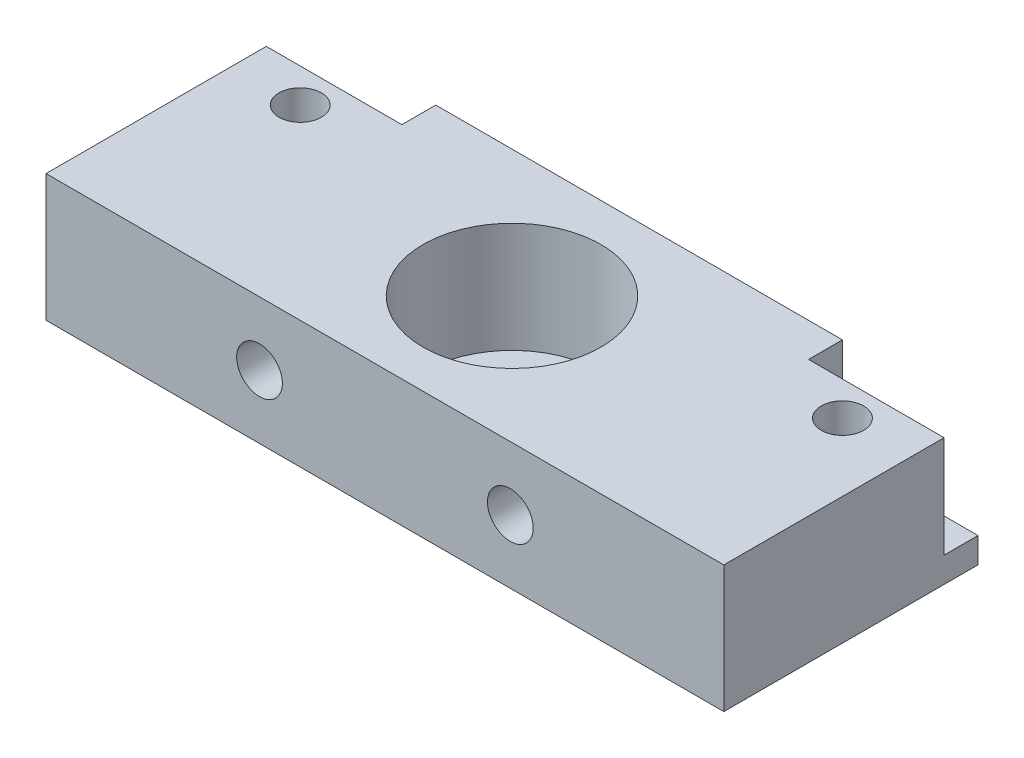
from build123d import *

# Parameters (mm, degrees)
SKETCH1_W           = 101.6
SKETCH1_H           = 38.1
BOSS_EXTRUDE1_DEPTH = 19.05
SKETCH2_R           = 3.175
CUT_EXTRUDE1_DEPTH  = 16.51
CUT_EXTRUDE2_REACH  = 40.1
SKETCH3_R           = 3.429
SKETCH4_R           = 13.335
CUT_EXTRUDE3_DEPTH  = 16.51
SKETCH5_R           = 3.556
CUT_EXTRUDE4_DEPTH  = 20.05
SKETCH6_W           = 20.32
SKETCH6_H           = 5.08
CUT_EXTRUDE5_DEPTH  = 15.24


with BuildPart() as part:
    # Sketch1 → Boss-Extrude1 (new body)
    with BuildSketch(Plane(origin=(0, 0, 0), x_dir=(1, 0, 0), z_dir=(0, 1, 0))):
        with Locations((12.918491372, -8.273443983)):
            Rectangle(SKETCH1_W, SKETCH1_H)
    extrude(amount=BOSS_EXTRUDE1_DEPTH)

    # Sketch2 → Cut-Extrude1 (cut)
    with BuildSketch(Plane(origin=(0, 19.05, 0), x_dir=(1, 0, 0), z_dir=(0, 1, 0))):
        with Locations((-27.721508628, 0.616556017)):
            Circle(SKETCH2_R)
        with Locations((53.558491372, 0.616556017)):
            Circle(SKETCH2_R)
    extrude(amount=-CUT_EXTRUDE1_DEPTH, mode=Mode.SUBTRACT)

    # Sketch3 → Cut-Extrude2 (cut, up to next)
    with BuildSketch(Plane.XY.offset(27.323443983), mode=Mode.PRIVATE) as cut_extrude2_sk1:
        with Locations((-5.877508628, 9.525)):
            Circle(SKETCH3_R)
    cut_extrude2_tool1 = extrude(cut_extrude2_sk1.sketch, amount=-CUT_EXTRUDE2_REACH, mode=Mode.PRIVATE) & part.part
    add(cut_extrude2_tool1.solids().sort_by_distance((-5.877509, 9.525, 27.323444))[0], mode=Mode.SUBTRACT)
    # Sketch3 → Cut-Extrude2 (cut, up to next)
    with BuildSketch(Plane.XY.offset(27.323443983), mode=Mode.PRIVATE) as cut_extrude2_sk2:
        with Locations((31.714491372, 9.525)):
            Circle(SKETCH3_R)
    cut_extrude2_tool2 = extrude(cut_extrude2_sk2.sketch, amount=-CUT_EXTRUDE2_REACH, mode=Mode.PRIVATE) & part.part
    add(cut_extrude2_tool2.solids().sort_by_distance((31.714491, 9.525, 27.323444))[0], mode=Mode.SUBTRACT)

    # Sketch4 → Cut-Extrude3 (cut)
    with BuildSketch(Plane(origin=(0, 19.05, 0), x_dir=(1, 0, 0), z_dir=(0, 1, 0))):
        with Locations((12.918491372, -8.273443983)):
            Circle(SKETCH4_R)
    extrude(amount=-CUT_EXTRUDE3_DEPTH, mode=Mode.SUBTRACT)

    # Sketch5 → Cut-Extrude4 (cut, through all)
    with BuildSketch(Plane(origin=(0, 19.05, 0), x_dir=(1, 0, 0), z_dir=(0, 1, 0))):
        with Locations((12.918491372, -8.273443983)):
            Circle(SKETCH5_R)
    extrude(amount=-CUT_EXTRUDE4_DEPTH, mode=Mode.SUBTRACT)

    # Sketch6 → Cut-Extrude5 (cut)
    with BuildSketch(Plane(origin=(0, 19.05, 0), x_dir=(1, 0, 0), z_dir=(0, 1, 0))):
        with Locations((-27.721508628, 8.236556017)):
            Rectangle(SKETCH6_W, SKETCH6_H)
        with Locations((53.558491372, 8.236556017)):
            Rectangle(SKETCH6_W, SKETCH6_H)
    extrude(amount=-CUT_EXTRUDE5_DEPTH, mode=Mode.SUBTRACT)


solid = part.part
